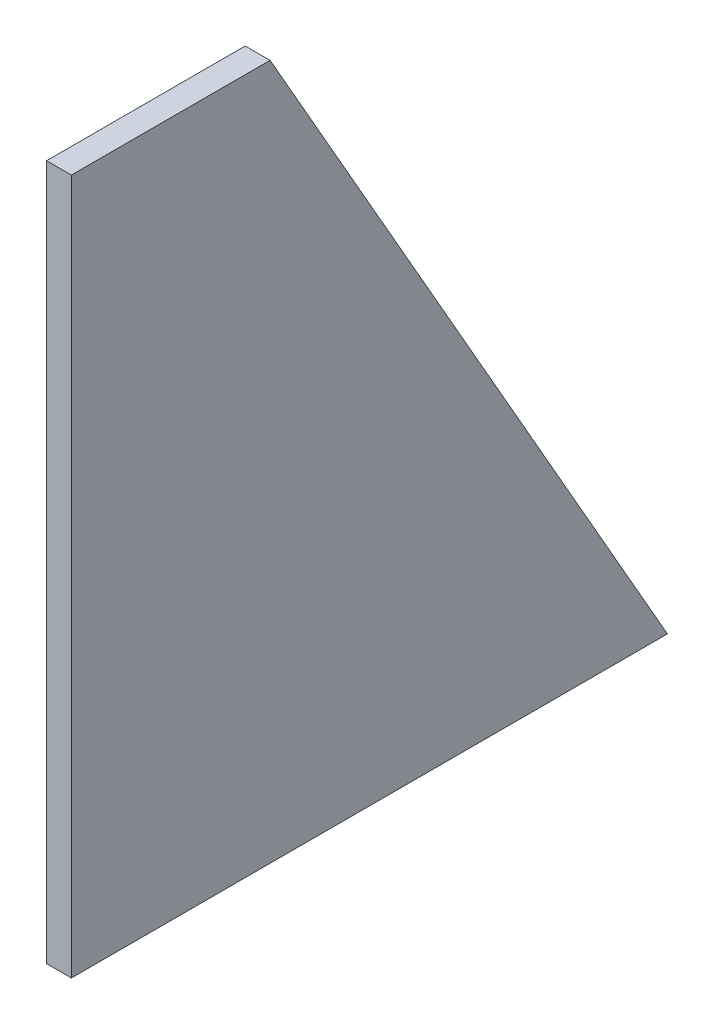
from build123d import *

# Parameters (mm, degrees)
BOSS_EXTRUDE1_DEPTH = 6.35


with BuildPart() as part:
    # Sketch1 → Boss-Extrude1 (new body)
    with BuildSketch(Plane(origin=(0, 0, 0), x_dir=(0, 0, -1), z_dir=(1, 0, 0))):
        Polygon((0, 0), (152.4, 0), (50.8, 177.8), (0, 177.8), align=None)
    extrude(amount=BOSS_EXTRUDE1_DEPTH)


solid = part.part
